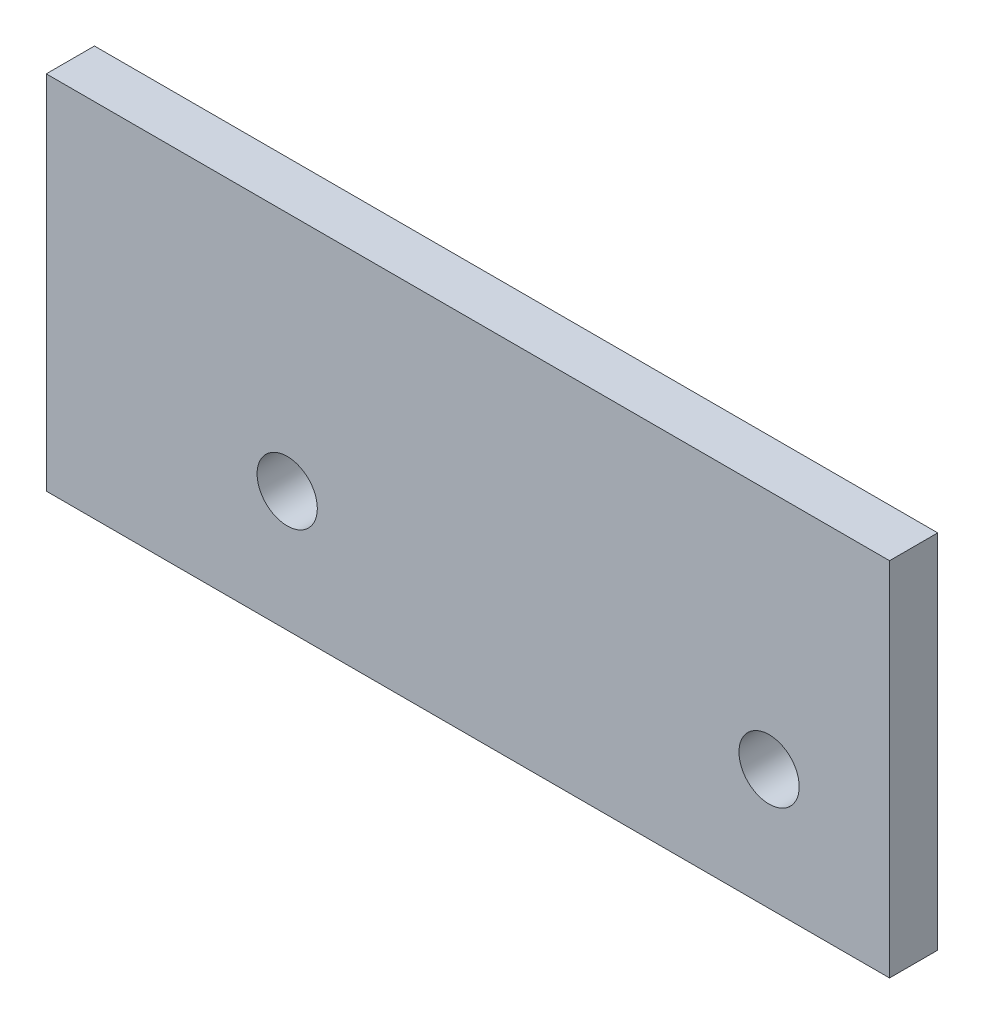
from build123d import *

# Parameters (mm, degrees)
SKETCH1_W           = 70
SKETCH1_H           = 30
SKETCH1_R           = 4
SKETCH1_R_2         = 2.5
BOSS_EXTRUDE1_DEPTH = 4
SKETCH1_3_R         = 4
SKETCH1_3_R_2       = 2.5
BOSS_EXTRUDE2_DEPTH = 16.063
CHAMFER1_SIZE       = 5


with BuildPart() as part:
    # Sketch1 → Boss-Extrude1 (new body)
    with BuildSketch(Plane.XY):
        with Locations((15, 5)):
            Rectangle(SKETCH1_W, SKETCH1_H)
        with Locations((40, 0)):
            Circle(SKETCH1_R, mode=Mode.SUBTRACT)
        Circle(SKETCH1_R, mode=Mode.SUBTRACT)
        with Locations((40, 0)):
            Circle(SKETCH1_R)
        with Locations((40, 0)):
            Circle(SKETCH1_R_2, mode=Mode.SUBTRACT)
    extrude(amount=-BOSS_EXTRUDE1_DEPTH)

    # Sketch1_3 → Boss-Extrude2 (add)
    with BuildSketch(Plane.XY):
        Circle(SKETCH1_3_R)
        Circle(SKETCH1_3_R_2, mode=Mode.SUBTRACT)
    extrude(amount=-BOSS_EXTRUDE2_DEPTH)

    # Chamfer1
    chamfer1_edges = [part.edges().sort_by_distance(p)[0] for p in [
        (-4, 0, -4),
    ]]
    chamfer(chamfer1_edges, length=CHAMFER1_SIZE)


solid = part.part
